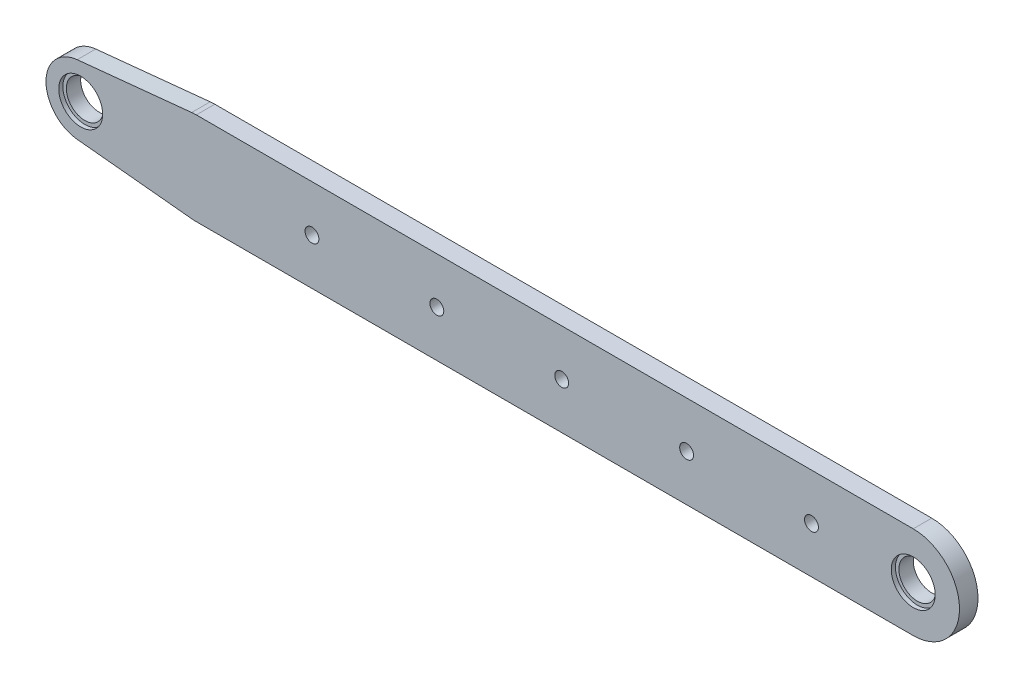
from build123d import *

# Parameters (mm, degrees)
EXTRUDE_1_DEPTH              = 4
HOLE_WIZARD_M5_1_D           = 8
HOLE_WIZARD_M5_1_CBORE_D     = 9.5
HOLE_WIZARD_M5_1_CBORE_DEPTH = 0.9
SKETCH_11_R                  = 1.5
CUT_EXTRUDE_1_DEPTH          = 1
CUT_EXTRUDE_1_DEPTH_BACK     = 5


with BuildPart() as part:
    # 草图1 → 凸台-拉伸1 (new body)
    with BuildSketch(Plane.XY):
        with BuildLine():
            Line((77.5, 10), (-77.5, 10))
            ThreePointArc((-77.5, 10), (-70.428932188, 7.071067812), (-67.5, 0))
            ThreePointArc((-67.5, 0), (-70.428932188, -7.071067812), (-77.5, -10))
            Line((-77.5, -10), (77.5, -10))
            ThreePointArc((77.5, -10), (87.5, 0), (77.5, 10))
        make_face()
        with BuildLine():
            ThreePointArc((-67.5, 0), (-70.428932188, 7.071067812), (-77.5, 10))
            ThreePointArc((-77.5, 10), (-78.000627751, 9.987460731), (-78.5, 9.949874371))
            ThreePointArc((-78.5, 9.949874371), (-87.5, 0), (-78.5, -9.949874371))
            ThreePointArc((-78.5, -9.949874371), (-78.000627751, -9.987460731), (-77.5, -10))
            ThreePointArc((-77.5, -10), (-70.428932188, -7.071067812), (-67.5, 0))
        make_face()
        with BuildLine():
            ThreePointArc((-78.5, -9.949874371), (-87.5, 0), (-78.5, 9.949874371))
            Line((-78.5, 9.949874371), (-103.25, 7.462405778))
            ThreePointArc((-103.25, 7.462405778), (-110, 0), (-103.25, -7.462405778))
            Line((-103.25, -7.462405778), (-78.5, -9.949874371))
        make_face()
    extrude(amount=EXTRUDE_1_DEPTH)

    # M5 六角头螺栓的柱形沉头孔1 (through all)
    with Locations(Plane.XY.offset(4)):
        with Locations((-102.5, 0), (77.5, 0)):
            CounterBoreHole(HOLE_WIZARD_M5_1_D / 2, HOLE_WIZARD_M5_1_CBORE_D / 2, HOLE_WIZARD_M5_1_CBORE_DEPTH)

    # 草图11 → 切除-拉伸1 (cut, two sides)
    with BuildSketch(Plane.XY.offset(4)) as cut_extrude_1_sk:
        with Locations((-52.5, 0)):
            Circle(SKETCH_11_R)
        with Locations((-25.5, 0)):
            Circle(SKETCH_11_R)
        with Locations((1.5, 0)):
            Circle(SKETCH_11_R)
        with Locations((28.5, 0)):
            Circle(SKETCH_11_R)
        with Locations((55.5, 0)):
            Circle(SKETCH_11_R)
    extrude(amount=CUT_EXTRUDE_1_DEPTH, mode=Mode.SUBTRACT)
    extrude(cut_extrude_1_sk.sketch, amount=-CUT_EXTRUDE_1_DEPTH_BACK, mode=Mode.SUBTRACT)


solid = part.part
